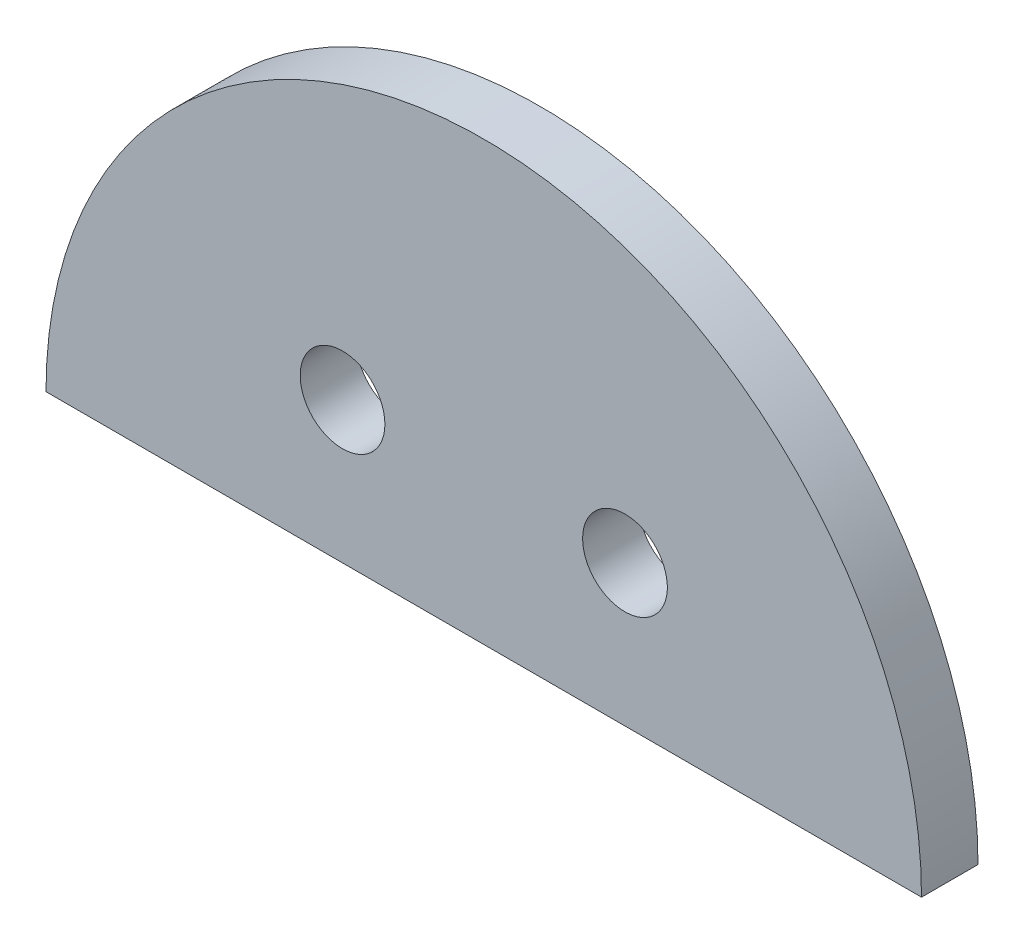
from build123d import *

# Parameters (mm, degrees)
SKETCH_1_R      = 1.5
EXTRUDE_1_DEPTH = 2


with BuildPart() as part:
    # 草图1 → 凸台-拉伸1 (new body)
    with BuildSketch(Plane.XY):
        with BuildLine():
            Line((-15.5, 0), (15.5, 0))
            ThreePointArc((15.5, 0), (0, 15.5), (-15.5, 0))
        make_face()
        with Locations((-5, 5)):
            Circle(SKETCH_1_R, mode=Mode.SUBTRACT)
        with Locations((5, 5)):
            Circle(SKETCH_1_R, mode=Mode.SUBTRACT)
    extrude(amount=EXTRUDE_1_DEPTH)


solid = part.part
